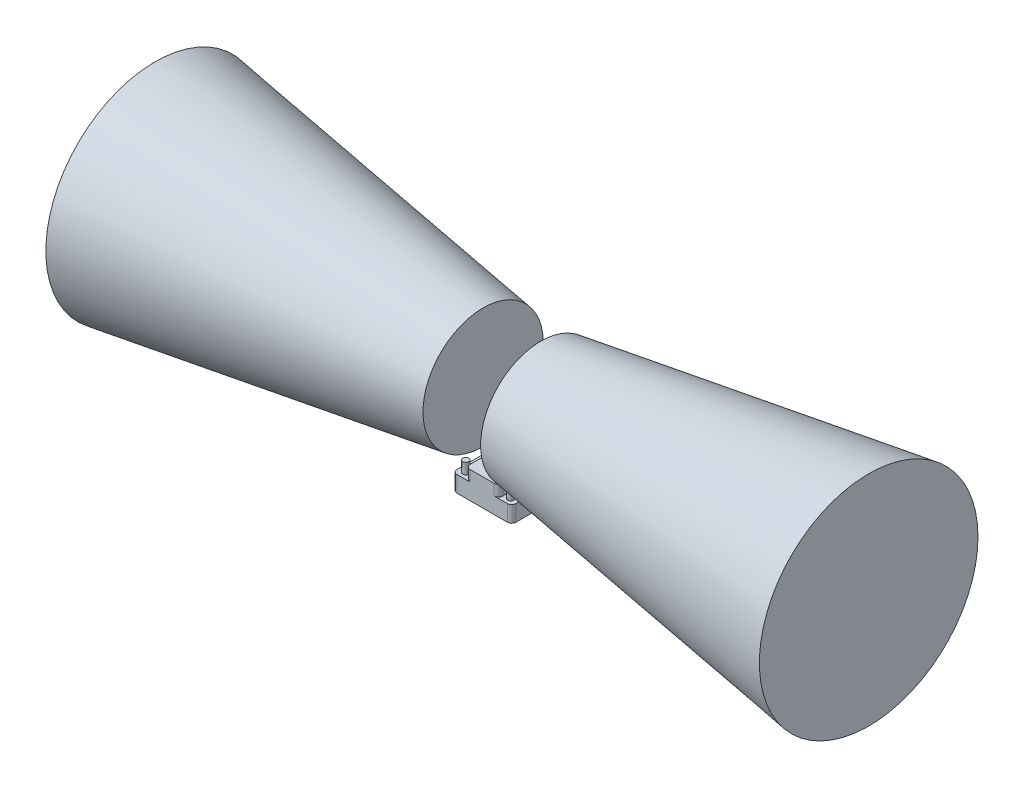
from build123d import *

# Parameters (mm, degrees)
BOSS_EXTRUDE1_DEPTH      = 4.8
BOSS_EXTRUDE1_DEPTH_BACK = 10
SKETCH2_R                = 2.75
BOSS_EXTRUDE2_DEPTH      = 10


with BuildPart() as part:
    # Sketch1 → Boss-Extrude1 (new body, two sides)
    with BuildSketch(Plane(origin=(0, 0, 0), x_dir=(1, 0, 0), z_dir=(0, 1, 0))) as boss_extrude1_sk:
        with BuildLine():
            Line((-23, -37.25), (23, -37.25))
            ThreePointArc((23, -37.25), (25.828427125, -36.078427125), (27, -33.25))
            Line((27, -33.25), (27, 33.25))
            ThreePointArc((27, 33.25), (25.828427125, 36.078427125), (23, 37.25))
            Line((23, 37.25), (-23, 37.25))
            ThreePointArc((-23, 37.25), (-25.828427125, 36.078427125), (-27, 33.25))
            Line((-27, 33.25), (-27, -33.25))
            ThreePointArc((-27, -33.25), (-25.828427125, -36.078427125), (-23, -37.25))
        make_face()
    extrude(amount=BOSS_EXTRUDE1_DEPTH)
    extrude(boss_extrude1_sk.sketch, amount=-BOSS_EXTRUDE1_DEPTH_BACK)

    # Sketch2 → Boss-Extrude2 (add)
    with BuildSketch(Plane(origin=(0, 4.8, 0), x_dir=(1, 0, 0), z_dir=(0, 1, 0))):
        with Locations((20.55, -31.625)):
            Circle(SKETCH2_R)
        with Locations((-20.55, -31.625)):
            Circle(SKETCH2_R)
        with Locations((-20.55, 21.625)):
            Circle(SKETCH2_R)
        with Locations((20.55, 21.625)):
            Circle(SKETCH2_R)
        with BuildLine():
            Line((-11, -37.25), (11, -37.25))
            ThreePointArc((11, -37.25), (13.828427125, -36.078427125), (15, -33.25))
            Line((15, -33.25), (15, 33.25))
            ThreePointArc((15, 33.25), (13.828427125, 36.078427125), (11, 37.25))
            Line((11, 37.25), (-11, 37.25))
            ThreePointArc((-11, 37.25), (-13.828427125, 36.078427125), (-15, 33.25))
            Line((-15, 33.25), (-15, -33.25))
            ThreePointArc((-15, -33.25), (-13.828427125, -36.078427125), (-11, -37.25))
        make_face()
    extrude(amount=BOSS_EXTRUDE2_DEPTH)


with BuildPart() as body_2:
    # Sketch3 → Revolve2 (revolve)
    with BuildSketch(Plane.XY.offset(10)):
        Polygon((26.374608886, 121.5), (326.374608886, 166.5), (326.374608886, 66.5), (26.374608886, 66.5), align=None)
        Polygon((-26.374608886, 66.5), (-26.374608886, 121.5), (-326.374608886, 166.5), (-326.374608886, 66.5), align=None)
    revolve(axis=Axis((-26.374608886, 66.5, 10), (-1, 0, 0)))


solid = Compound([part.part, body_2.part])
